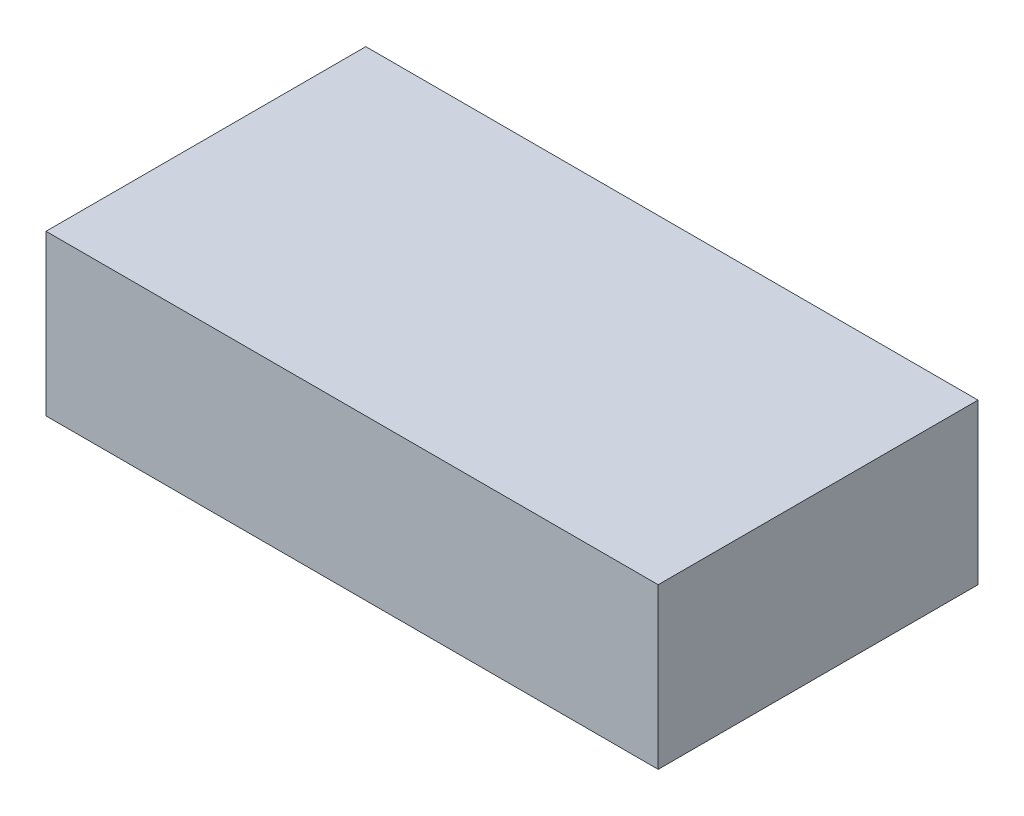
from build123d import *

# Parameters (mm, degrees)
SKETCH1_W           = 134
SKETCH1_H           = 70
BOSS_EXTRUDE1_DEPTH = 35


with BuildPart() as part:
    # Sketch1 → Boss-Extrude1 (new body)
    with BuildSketch(Plane(origin=(0, 0, 0), x_dir=(1, 0, 0), z_dir=(0, 1, 0))):
        with Locations((11.940711462, -9.960474308)):
            Rectangle(SKETCH1_W, SKETCH1_H)
    extrude(amount=BOSS_EXTRUDE1_DEPTH)


solid = part.part
